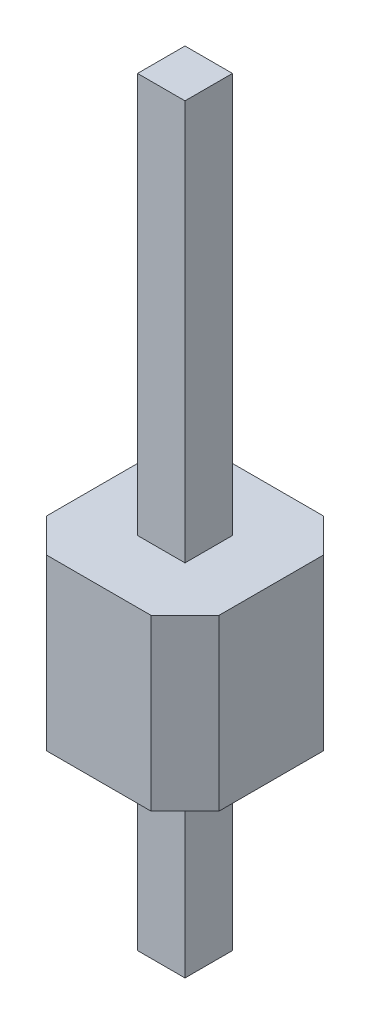
from build123d import *

# Parameters (mm, degrees)
SKETCH1_W           = 0.7
SKETCH1_H           = 0.7
BOSS_EXTRUDE1_DEPTH = 11.2
BOSS_EXTRUDE2_START = 2.8
SKETCH1_3_W         = 2.54
SKETCH1_3_H         = 2.54
SKETCH1_3_W_2       = 0.7
SKETCH1_3_H_2       = 0.7
BOSS_EXTRUDE2_DEPTH = 2.5
CHAMFER1_SIZE       = 0.5


with BuildPart() as part:
    # Sketch1 → Boss-Extrude1 (new body)
    with BuildSketch(Plane(origin=(0, 0, 0), x_dir=(1, 0, 0), z_dir=(0, 1, 0))):
        with Locations((1.27, 1.27)):
            Rectangle(SKETCH1_W, SKETCH1_H)
    extrude(amount=BOSS_EXTRUDE1_DEPTH)

    # Sketch1_3 → Boss-Extrude2 (add)
    with BuildSketch(Plane(origin=(0, 0, 0), x_dir=(1, 0, 0), z_dir=(0, 1, 0)).offset(BOSS_EXTRUDE2_START)):
        with Locations((1.27, 1.27)):
            Rectangle(SKETCH1_3_W, SKETCH1_3_H)
        with Locations((1.27, 1.27)):
            Rectangle(SKETCH1_3_W_2, SKETCH1_3_H_2, mode=Mode.SUBTRACT)
    extrude(amount=BOSS_EXTRUDE2_DEPTH)

    # Chamfer1
    chamfer1_edges = [part.edges().sort_by_distance(p)[0] for p in [
        (0, 4.05, 0),
        (0, 4.05, -2.54),
        (2.54, 4.05, 0),
        (2.54, 4.05, -2.54),
    ]]
    chamfer(chamfer1_edges, length=CHAMFER1_SIZE)


solid = part.part
